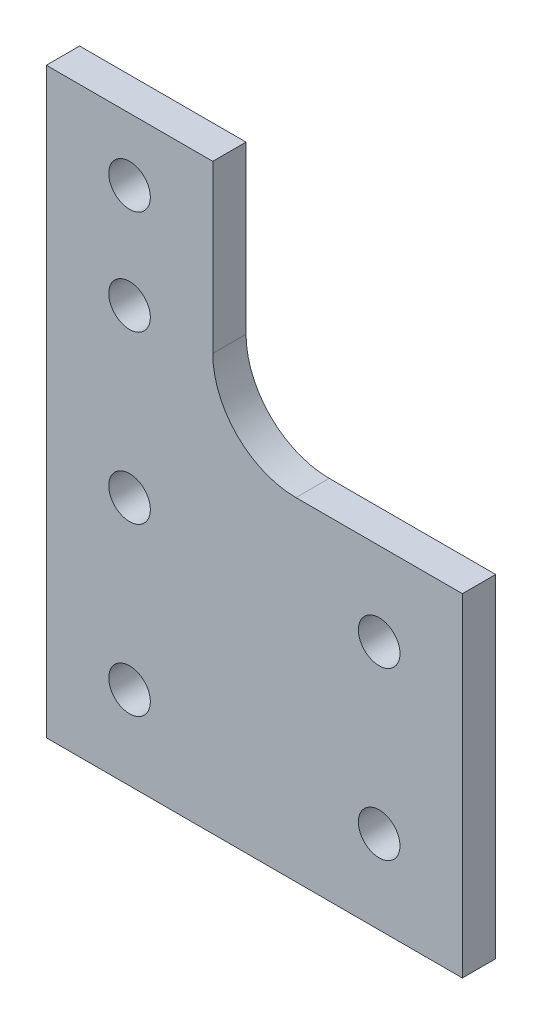
from build123d import *

# Parameters (mm, degrees)
SKETCH1_R           = 2.5
BOSS_EXTRUDE1_DEPTH = 4


with BuildPart() as part:
    # Sketch1 → Boss-Extrude1 (new body)
    with BuildSketch(Plane.XY):
        with BuildLine():
            Line((-20, -30), (-20, 40))
            Line((-20, 40), (0, 40))
            Line((0, 40), (0, 20))
            ThreePointArc((0, 20), (2.928932188, 12.928932188), (10, 10))
            Line((10, 10), (30, 10))
            Line((30, 10), (30, -30))
            Line((30, -30), (-20, -30))
        make_face()
        with Locations((-10, 32.5)):
            Circle(SKETCH1_R, mode=Mode.SUBTRACT)
        with Locations((-10, 0)):
            Circle(SKETCH1_R, mode=Mode.SUBTRACT)
        with Locations((-10, -20)):
            Circle(SKETCH1_R, mode=Mode.SUBTRACT)
        with Locations((20, 0)):
            Circle(SKETCH1_R, mode=Mode.SUBTRACT)
        with Locations((20, -20)):
            Circle(SKETCH1_R, mode=Mode.SUBTRACT)
        with Locations((-10, 20)):
            Circle(SKETCH1_R, mode=Mode.SUBTRACT)
    extrude(amount=BOSS_EXTRUDE1_DEPTH)


solid = part.part
